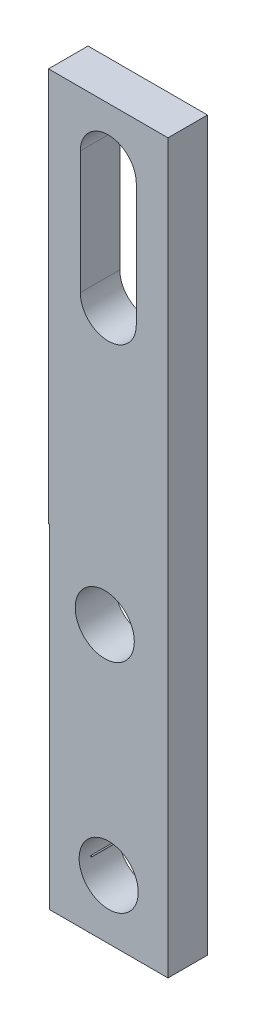
from build123d import *

# Parameters (mm, degrees)
BOSS_EXTRUDE1_DEPTH = 2.54
SKETCH2_R           = 1.89865
SKETCH2_R_2         = 2.356522007
SKETCH2_R_3         = 0.039656004
CUT_EXTRUDE1_DEPTH  = 4.572
CUT_EXTRUDE2_DEPTH  = 2.54


with BuildPart() as part:
    # Sketch3 → Boss-Extrude1 (new body)
    with BuildSketch(Plane.XY):
        Polygon((-30.711579586, -81.467357182), (-30.711579586, -102.917357182), (-23.091579586, -102.917357182), (-23.091579586, -56.153840626), (-30.770178896, -56.153840626), (-30.770178896, -81.467357182), align=None)
    extrude(amount=BOSS_EXTRUDE1_DEPTH)

    # Sketch2 → Cut-Extrude1 (cut)
    with BuildSketch(Plane.XY):
        with Locations((-27.154806567, -85.277357182)):
            Circle(SKETCH2_R)
        Circle(SKETCH2_R_2)
        with Locations((-26.901579586, -99.107357182)):
            Circle(SKETCH2_R)
        with Locations((-28.03226704, -98.616862848)):
            Circle(SKETCH2_R_3, mode=Mode.SUBTRACT)
    extrude(amount=CUT_EXTRUDE1_DEPTH, mode=Mode.SUBTRACT)

    # Sketch4 → Cut-Extrude2 (cut)
    with BuildSketch(Plane.XY.offset(2.54)):
        with BuildLine():
            Line((-28.728652743, -59.707357268), (-28.728652743, -67.588775762))
            ThreePointArc((-28.728652743, -67.588775762), (-26.928652787, -69.388775718), (-25.128652831, -67.588775762))
            Line((-25.128652831, -67.588775762), (-25.128652831, -59.707357268))
            ThreePointArc((-25.128652831, -59.707357268), (-26.928652787, -57.907357312), (-28.728652743, -59.707357268))
        make_face()
    extrude(amount=-CUT_EXTRUDE2_DEPTH, mode=Mode.SUBTRACT)


solid = part.part
